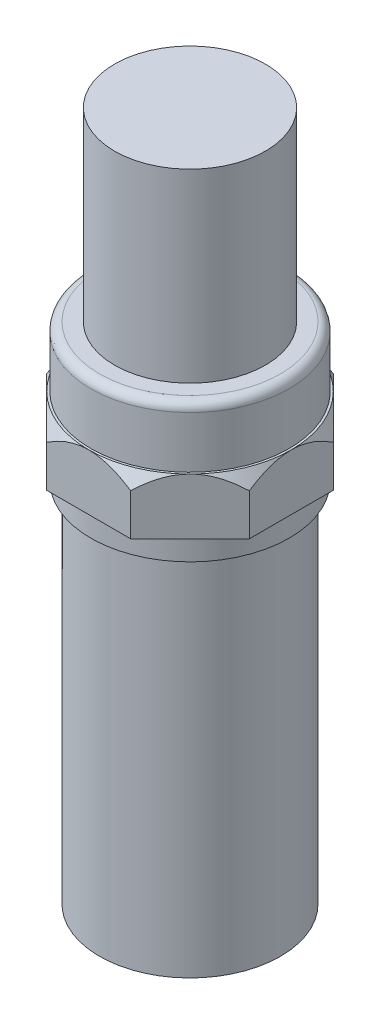
from build123d import *

# Parameters (mm, degrees)
SKETCH1_R           = 21
SKETCH1_R_2         = 20
EXTRUDE_THIN1_DEPTH = 85
SKETCH2_R           = 23
SKETCH2_R_2         = 21
EXTRUDE_THIN2_DEPTH = 5
SKETCH3_R           = 23
EXTRUDE1_DEPTH      = 13
SKETCH7_R           = 23
EXTRUDE3_DEPTH      = 14
SKETCH11_R          = 2
EXTRUDE5_DEPTH      = 30
SKETCH12_R          = 12.5
EXTRUDE6_DEPTH      = 3
SKETCH9_R           = 17.5
EXTRUDE4_DEPTH      = 43
FILLET1_R           = 2


with BuildPart() as part:
    # Sketch1 → Extrude-Thin1 (new body)
    with BuildSketch(Plane(origin=(0, 0, 0), x_dir=(1, 0, 0), z_dir=(0, 1, 0))):
        Circle(SKETCH1_R)
        Circle(SKETCH1_R_2, mode=Mode.SUBTRACT)
    extrude(amount=EXTRUDE_THIN1_DEPTH)


with BuildPart() as body_2:
    # Sketch2 → Extrude-Thin2 (new body)
    with BuildSketch(Plane(origin=(0, 85, 0), x_dir=(1, 0, 0), z_dir=(0, 1, 0))):
        Circle(SKETCH2_R)
        Circle(SKETCH2_R_2, mode=Mode.SUBTRACT)
    extrude(amount=EXTRUDE_THIN2_DEPTH)


with BuildPart() as body_3:
    # Sketch3 → Extrude1 (new body)
    with BuildSketch(Plane(origin=(0, 90, 0), x_dir=(1, 0, 0), z_dir=(0, 1, 0))):
        Polygon((-23.5, -9.734018716), (-9.734018716, -23.5), (9.734018716, -23.5), (23.5, -9.734018716), (23.5, 9.734018716), (9.734018716, 23.5), (-9.734018716, 23.5), (-23.5, 9.734018716), align=None)
        Circle(SKETCH3_R, mode=Mode.SUBTRACT)
    extrude(amount=EXTRUDE1_DEPTH)

    # Cut-Sweep2: sweep along a path in Sketch6
    with BuildLine(Plane(origin=(0, 103, 0), x_dir=(1, 0, 0), z_dir=(0, 1, 0))) as cut_sweep2_path:
        CenterArc((0, 0), 30, 0, 360)
    # Sketch5 → Cut-Sweep2 (sweep, cut)
    with BuildSketch(Plane.XY):
        Polygon((26.386751346, 103), (26.386751346, 98), (23.5, 103), align=None)
    sweep(path=cut_sweep2_path.line, mode=Mode.SUBTRACT)


with BuildPart() as body_4:
    # Sketch7 → Extrude3 (new body)
    with BuildSketch(Plane(origin=(0, 103, 0), x_dir=(1, 0, 0), z_dir=(0, 1, 0))):
        Circle(SKETCH7_R)
    extrude(amount=EXTRUDE3_DEPTH)

    # Sketch11 → Extrude5 (add)
    with BuildSketch(Plane(origin=(0, 117, 0), x_dir=(1, 0, 0), z_dir=(0, 1, 0))):
        Circle(SKETCH11_R)
    extrude(amount=EXTRUDE5_DEPTH)

    # Sketch12 → Extrude6 (add)
    with BuildSketch(Plane(origin=(0, 147, 0), x_dir=(1, 0, 0), z_dir=(0, 1, 0))):
        Circle(SKETCH12_R)
    extrude(amount=EXTRUDE6_DEPTH)

    # Fillet1
    fillet1_edges = [body_4.edges().sort_by_distance(p)[0] for p in [
        (-23, 117, 0),
    ]]
    fillet(fillet1_edges, radius=FILLET1_R)


with BuildPart() as body_5:
    # Sketch9 → Extrude4 (new body)
    with BuildSketch(Plane(origin=(0, 117, 0), x_dir=(1, 0, 0), z_dir=(0, 1, 0))):
        Circle(SKETCH9_R)
    extrude(amount=EXTRUDE4_DEPTH)


solid = Compound([part.part, body_2.part, body_3.part, body_4.part, body_5.part])
